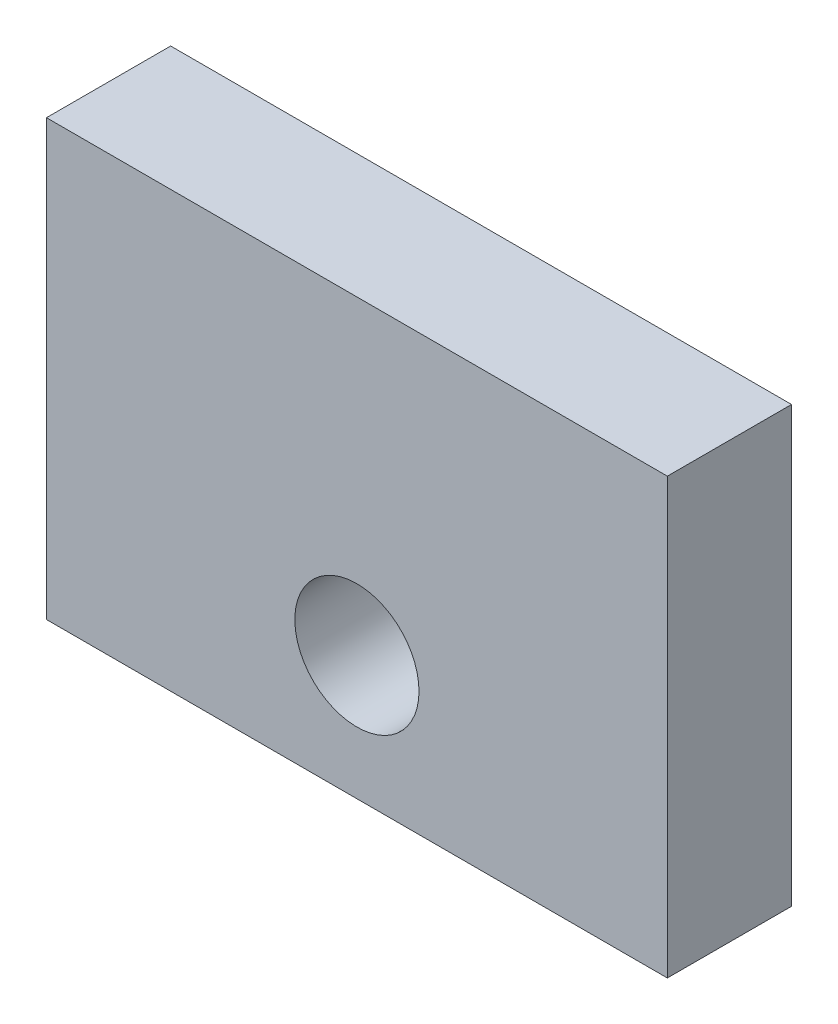
from build123d import *

# Parameters (mm, degrees)
SKETCH1_W           = 10
SKETCH1_H           = 7
SKETCH1_R           = 1
BOSS_EXTRUDE1_DEPTH = 2


with BuildPart() as part:
    # Sketch1 → Boss-Extrude1 (new body)
    with BuildSketch(Plane.XY):
        with Locations((5, 3.5)):
            Rectangle(SKETCH1_W, SKETCH1_H)
        with Locations((5, 2)):
            Circle(SKETCH1_R, mode=Mode.SUBTRACT)
    extrude(amount=BOSS_EXTRUDE1_DEPTH)


solid = part.part
